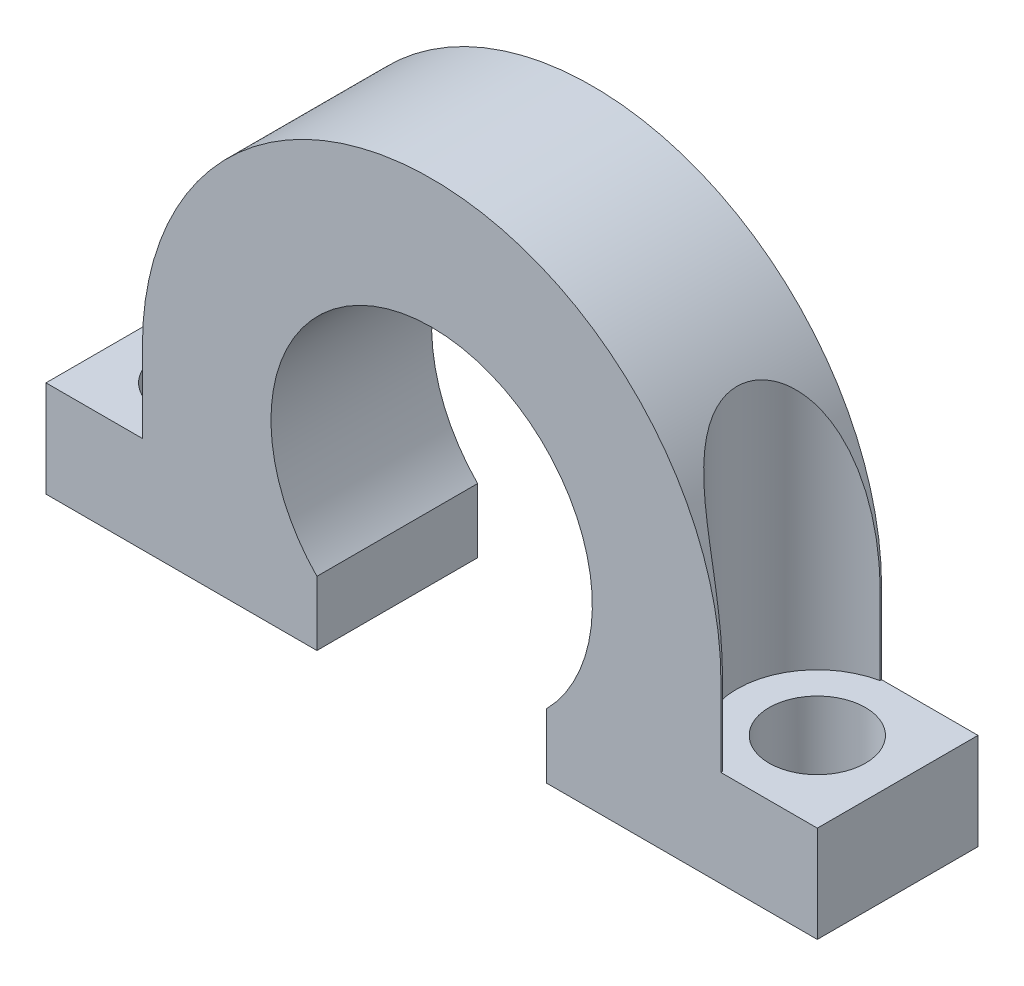
from build123d import *

# Parameters (mm, degrees)
RESSALTO_EXTRUS_O1_DEPTH   = 5
ESBO_O2_R                  = 1.5
CORTE_EXTRUS_O1_DEPTH      = 12.5
CORTE_EXTRUS_O1_DEPTH_BACK = 4
ESBO_O3_R                  = 2.5
CORTE_EXTRUS_O2_DEPTH      = 12.5000001


with BuildPart() as part:
    # Esboço1 → Ressalto-extrusão1 (new body)
    with BuildSketch(Plane.XY):
        with BuildLine():
            Line((-9, -2.5), (-9, 0))
            ThreePointArc((-9, 0), (0, 9), (9, 0))
            Line((9, 0), (9, -2.5))
            Line((9, -2.5), (12, -2.5))
            Line((12, -2.5), (12, -5.5))
            Line((12, -5.5), (3.570714214, -5.5))
            Line((3.570714214, -5.5), (3.570714214, -3.5))
            ThreePointArc((3.570714214, -3.5), (0, 5), (-3.570714214, -3.5))
            Line((-3.570714214, -3.5), (-3.570714214, -5.5))
            Line((-3.570714214, -5.5), (-12, -5.5))
            Line((-12, -5.5), (-12, -2.5))
            Line((-12, -2.5), (-9, -2.5))
        make_face()
    extrude(amount=RESSALTO_EXTRUS_O1_DEPTH)

    # Esboço2 → Corte-extrusão1 (cut, two sides)
    with BuildSketch(Plane(origin=(0, -2.5, 0), x_dir=(1, 0, 0), z_dir=(0, 1, 0))) as corte_extrus_o1_sk:
        with Locations((-9.5, -2.5)):
            Circle(ESBO_O2_R)
        with Locations((9.5, -2.5)):
            Circle(ESBO_O2_R)
    extrude(amount=CORTE_EXTRUS_O1_DEPTH, mode=Mode.SUBTRACT)
    extrude(corte_extrus_o1_sk.sketch, amount=-CORTE_EXTRUS_O1_DEPTH_BACK, mode=Mode.SUBTRACT)

    # Esboço3 → Corte-extrusão2 (cut, through all)
    with BuildSketch(Plane(origin=(0, -2.5, 0), x_dir=(1, 0, 0), z_dir=(0, 1, 0))):
        with Locations((-9.5, -2.5)):
            Circle(ESBO_O3_R)
        with Locations((9.5, -2.5)):
            Circle(ESBO_O3_R)
    extrude(amount=CORTE_EXTRUS_O2_DEPTH, mode=Mode.SUBTRACT)


solid = part.part
